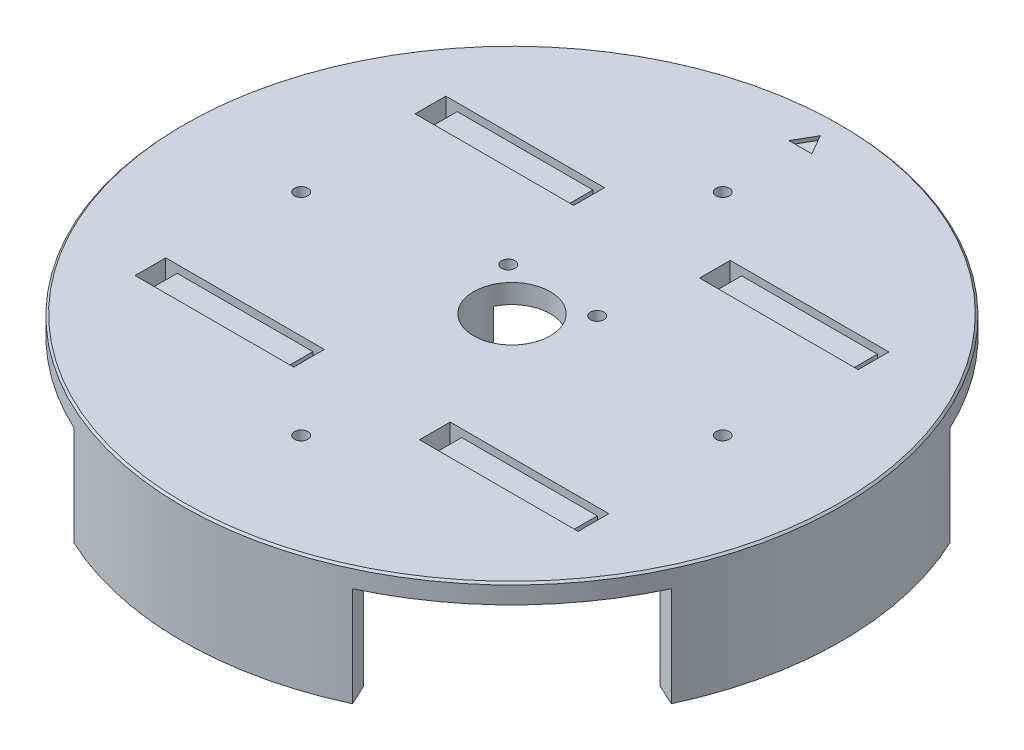
from build123d import *
from build123d.topology import SkipClean

# Parameters (mm, degrees)
SKIZZE1_R                       = 86
AUFSATZ_LINEAR_AUSTRAGEN1_DEPTH = 5
AUFSATZ_LINEAR_START            = 26
AUFSATZ_LINEAR_AUSTRAGEN2_DEPTH = 26
KREISMUSTER1_COUNT              = 4
SCHNITT_LINEAR_AUSTRAGEN1_REACH = 126.37
SKIZZE4_R                       = 10
AUFSATZ_LINEAR_AUSTRAGEN5_DEPTH = 26
SKIZZE6_R                       = 1.35
SCHNITT_LINEAR_AUSTRAGEN2_DEPTH = 10
KREISMUSTER2_COUNT              = 4
VERRUNDUNG3_R                   = 3
SCHNITT_LINEAR_AUSTRAGEN4_REACH = 126.37
SKIZZE10_W                      = 3
SKIZZE10_H                      = 8
FASE1_SIZE                      = 0.5
SCHNITT_LINEAR_AUSTRAGEN5_DEPTH = 1
SKIZZE12_R                      = 1.75
SCHNITT_LINEAR_AUSTRAGEN6_DEPTH = 5
SKIZZE13_W                      = 35.4
SKIZZE13_H                      = 8
SCHNITT_LINEAR_AUSTRAGEN7_DEPTH = 2


with BuildPart() as part:
    # Skizze1 → Aufsatz-Linear austragen1 (new body)
    with BuildSketch(Plane(origin=(0, 0, 0), x_dir=(1, 0, 0), z_dir=(0, 1, 0))):
        with Locations(Location((0, 0, 0), (0, 0, 270))):
            Circle(SKIZZE1_R)
    extrude(amount=AUFSATZ_LINEAR_AUSTRAGEN1_DEPTH)

    # Skizze2 → Aufsatz-Linear austragen2 (add)
    with SkipClean():  # the faces are left unmerged after this step: merging them gives an invalid solid
        with BuildSketch(Plane.XZ.offset(AUFSATZ_LINEAR_START)):
            with BuildLine():
                Line((-36.345171, 77.94247), (-33.809461, 72.504623))
                ThreePointArc((-33.809461, 72.504623), (0, 80), (33.809461, 72.504623))
                Line((33.809461, 72.504623), (36.345171, 77.94247))
                ThreePointArc((36.345171, 77.94247), (0, 86), (-36.345171, 77.94247))
            make_face()
        aufsatz_linear_austragen2 = extrude(amount=-AUFSATZ_LINEAR_AUSTRAGEN2_DEPTH)

    # Kreismuster1: Aufsatz-Linear austragen2 ×4 about axis
    with SkipClean():  # the faces are left unmerged after this step: merging them gives an invalid solid
        kreismuster1_axis = Axis((0, -99.932475, 0), (0, 1, 0))
        for i in range(1, KREISMUSTER1_COUNT):
            add(aufsatz_linear_austragen2.rotate(kreismuster1_axis, i * 360 / KREISMUSTER1_COUNT))

    # Skizze4 → Schnitt-Linear austragen1 (cut, up to next)
    with BuildSketch(Plane.XZ, mode=Mode.PRIVATE) as schnitt_linear_austragen1_sk1:
        with Locations(Location((0, 0, 0), (0, 0, 270))):
            Circle(SKIZZE4_R)
    schnitt_linear_austragen1_tool1 = extrude(schnitt_linear_austragen1_sk1.sketch, amount=-SCHNITT_LINEAR_AUSTRAGEN1_REACH, mode=Mode.PRIVATE) & part.part
    add(schnitt_linear_austragen1_tool1.solids().sort_by_distance((0, 0, 0))[0], mode=Mode.SUBTRACT)

    # Skizze7 → Aufsatz-Linear austragen5 (add)
    with SkipClean():  # the faces are left unmerged after this step: merging them gives an invalid solid
        with BuildSketch(Plane.XZ.offset(AUFSATZ_LINEAR_START)):
            with BuildLine():
                Line((-9.063078, 4.226183), (-11.782001, 5.494037))
                ThreePointArc((-11.782001, 5.494037), (-13, 0), (-11.782001, -5.494037))
                Line((-11.782001, -5.494037), (-9.063078, -4.226183))
                ThreePointArc((-9.063078, -4.226183), (-10, 0), (-9.063078, 4.226183))
            make_face()
            with BuildLine():
                ThreePointArc((13, 0), (12.691848, 2.813715), (11.782001, 5.494037))
                Line((11.782001, 5.494037), (9.063078, 4.226183))
                ThreePointArc((9.063078, 4.226183), (9.76296, 2.164396), (10, 0))
                ThreePointArc((10, 0), (9.76296, -2.164396), (9.063078, -4.226183))
                Line((9.063078, -4.226183), (11.782001, -5.494037))
                ThreePointArc((11.782001, -5.494037), (12.691848, -2.813715), (13, 0))
            make_face()
        extrude(amount=-AUFSATZ_LINEAR_AUSTRAGEN5_DEPTH)

    # Skizze6 → Schnitt-Linear austragen2 (cut)
    with SkipClean():  # the faces are left unmerged after this step: merging them gives an invalid solid
        with BuildSketch(Plane.XZ.offset(26)):
            with Locations(Location((-21.456083, 80.075191, 0), (0, 0, 270))):
                Circle(SKIZZE6_R)
            with Locations(Location((21.456083, 80.075191, 0), (0, 0, 270))):
                Circle(SKIZZE6_R)
        schnitt_linear_austragen2 = extrude(amount=-SCHNITT_LINEAR_AUSTRAGEN2_DEPTH, mode=Mode.SUBTRACT)

    # Kreismuster2: Schnitt-Linear austragen2 ×4 about axis
    with SkipClean():  # the faces are left unmerged after this step: merging them gives an invalid solid
        kreismuster2_axis = Axis((0, 0, 0), (0, 1, 0))
        for i in range(1, KREISMUSTER2_COUNT):
            add(schnitt_linear_austragen2.rotate(kreismuster2_axis, i * 360 / KREISMUSTER2_COUNT), mode=Mode.SUBTRACT)

    # Verrundung3
    verrundung3_edges = [part.edges().sort_by_distance(p)[0] for p in [
        (80, 0, 0),
        (0, 0, -80),
        (-80, 0, 0),
        (-13, 0, 0),
        (13, 0, 0),
        (0, 0, 80),
    ]]
    fillet(verrundung3_edges, radius=VERRUNDUNG3_R)

    # Skizze10 → Schnitt-Linear austragen4 (cut, up to next)
    with BuildSketch(Plane.XZ, mode=Mode.PRIVATE) as schnitt_linear_austragen4_sk1:
        with Locations((56.312567, 36.541606)):
            Rectangle(SKIZZE10_W, SKIZZE10_H)
    schnitt_linear_austragen4_tool1 = extrude(schnitt_linear_austragen4_sk1.sketch, amount=-SCHNITT_LINEAR_AUSTRAGEN4_REACH, mode=Mode.PRIVATE) & part.part
    # Skizze10 → Schnitt-Linear austragen4 (cut, up to next)
    with BuildSketch(Plane.XZ, mode=Mode.PRIVATE) as schnitt_linear_austragen4_sk2:
        with Locations((17.912567, 36.541606)):
            Rectangle(SKIZZE10_W, SKIZZE10_H)
    schnitt_linear_austragen4_tool2 = extrude(schnitt_linear_austragen4_sk2.sketch, amount=-SCHNITT_LINEAR_AUSTRAGEN4_REACH, mode=Mode.PRIVATE) & part.part
    # Skizze10 → Schnitt-Linear austragen4 (cut, up to next)
    with BuildSketch(Plane.XZ, mode=Mode.PRIVATE) as schnitt_linear_austragen4_sk3:
        with Locations((-17.912567, 36.541606)):
            Rectangle(SKIZZE10_W, SKIZZE10_H)
    schnitt_linear_austragen4_tool3 = extrude(schnitt_linear_austragen4_sk3.sketch, amount=-SCHNITT_LINEAR_AUSTRAGEN4_REACH, mode=Mode.PRIVATE) & part.part
    # Skizze10 → Schnitt-Linear austragen4 (cut, up to next)
    with BuildSketch(Plane.XZ, mode=Mode.PRIVATE) as schnitt_linear_austragen4_sk4:
        with Locations((-56.312567, 36.541606)):
            Rectangle(SKIZZE10_W, SKIZZE10_H)
    schnitt_linear_austragen4_tool4 = extrude(schnitt_linear_austragen4_sk4.sketch, amount=-SCHNITT_LINEAR_AUSTRAGEN4_REACH, mode=Mode.PRIVATE) & part.part
    # Skizze10 → Schnitt-Linear austragen4 (cut, up to next)
    with BuildSketch(Plane.XZ, mode=Mode.PRIVATE) as schnitt_linear_austragen4_sk5:
        with Locations((56.312567, -36.541606)):
            Rectangle(SKIZZE10_W, SKIZZE10_H)
    schnitt_linear_austragen4_tool5 = extrude(schnitt_linear_austragen4_sk5.sketch, amount=-SCHNITT_LINEAR_AUSTRAGEN4_REACH, mode=Mode.PRIVATE) & part.part
    # Skizze10 → Schnitt-Linear austragen4 (cut, up to next)
    with BuildSketch(Plane.XZ, mode=Mode.PRIVATE) as schnitt_linear_austragen4_sk6:
        with Locations((17.912567, -36.541606)):
            Rectangle(SKIZZE10_W, SKIZZE10_H)
    schnitt_linear_austragen4_tool6 = extrude(schnitt_linear_austragen4_sk6.sketch, amount=-SCHNITT_LINEAR_AUSTRAGEN4_REACH, mode=Mode.PRIVATE) & part.part
    # Skizze10 → Schnitt-Linear austragen4 (cut, up to next)
    with BuildSketch(Plane.XZ, mode=Mode.PRIVATE) as schnitt_linear_austragen4_sk7:
        with Locations((-17.912567, -36.541606)):
            Rectangle(SKIZZE10_W, SKIZZE10_H)
    schnitt_linear_austragen4_tool7 = extrude(schnitt_linear_austragen4_sk7.sketch, amount=-SCHNITT_LINEAR_AUSTRAGEN4_REACH, mode=Mode.PRIVATE) & part.part
    # Skizze10 → Schnitt-Linear austragen4 (cut, up to next)
    with BuildSketch(Plane.XZ, mode=Mode.PRIVATE) as schnitt_linear_austragen4_sk8:
        with Locations((-56.312567, -36.541606)):
            Rectangle(SKIZZE10_W, SKIZZE10_H)
    schnitt_linear_austragen4_tool8 = extrude(schnitt_linear_austragen4_sk8.sketch, amount=-SCHNITT_LINEAR_AUSTRAGEN4_REACH, mode=Mode.PRIVATE) & part.part
    add(schnitt_linear_austragen4_tool1.solids().sort_by_distance((56.312567, 0, 36.541606))[0], mode=Mode.SUBTRACT)
    add(schnitt_linear_austragen4_tool2.solids().sort_by_distance((17.912567, 0, 36.541606))[0], mode=Mode.SUBTRACT)
    add(schnitt_linear_austragen4_tool3.solids().sort_by_distance((-17.912567, 0, 36.541606))[0], mode=Mode.SUBTRACT)
    add(schnitt_linear_austragen4_tool4.solids().sort_by_distance((-56.312567, 0, 36.541606))[0], mode=Mode.SUBTRACT)
    add(schnitt_linear_austragen4_tool5.solids().sort_by_distance((56.312567, 0, -36.541606))[0], mode=Mode.SUBTRACT)
    add(schnitt_linear_austragen4_tool6.solids().sort_by_distance((17.912567, 0, -36.541606))[0], mode=Mode.SUBTRACT)
    add(schnitt_linear_austragen4_tool7.solids().sort_by_distance((-17.912567, 0, -36.541606))[0], mode=Mode.SUBTRACT)
    add(schnitt_linear_austragen4_tool8.solids().sort_by_distance((-56.312567, 0, -36.541606))[0], mode=Mode.SUBTRACT)

    # Fase1
    fase1_edges = [part.edges().sort_by_distance(p)[0] for p in [
        (0, 5, -86),
    ]]
    chamfer(fase1_edges, length=FASE1_SIZE)

    # Skizze11 → Schnitt-Linear austragen5 (cut)
    with SkipClean():  # the faces are left unmerged after this step: merging them gives an invalid solid
        with BuildSketch(Plane(origin=(0, 5, 0), x_dir=(1, 0, 0), z_dir=(0, 1, 0))):
            Polygon((3, 75.267949), (0, 80.464102), (-3, 75.267949), align=None)
        extrude(amount=-SCHNITT_LINEAR_AUSTRAGEN5_DEPTH, mode=Mode.SUBTRACT)

    # Skizze12 → Schnitt-Linear austragen6 (cut)
    with SkipClean():  # the faces are left unmerged after this step: merging them gives an invalid solid
        with BuildSketch(Plane.XZ):
            with Locations(Location((-55, 0, 0), (0, 0, 270))):
                Circle(SKIZZE12_R)
            with Locations(Location((0, -55, 0), (0, 0, 270))):
                Circle(SKIZZE12_R)
            with Locations(Location((55, 0, 0), (0, 0, 270))):
                Circle(SKIZZE12_R)
            with Locations(Location((0, 55, 0), (0, 0, 270))):
                Circle(SKIZZE12_R)
            with Locations(Location((-11.605237, -10.644187, 0), (0, 0, 270))):
                Circle(SKIZZE12_R)
            with Locations(Location((11.605237, -10.644187, 0), (0, 0, 270))):
                Circle(SKIZZE12_R)
        extrude(amount=-SCHNITT_LINEAR_AUSTRAGEN6_DEPTH, mode=Mode.SUBTRACT)

    # Skizze13 → Schnitt-Linear austragen7 (cut)
    with SkipClean():  # the faces are left unmerged after this step: merging them gives an invalid solid
        with BuildSketch(Plane(origin=(0, 5, 0), x_dir=(1, 0, 0), z_dir=(0, 1, 0))):
            with Locations((-37.112567, 36.541606)):
                Rectangle(SKIZZE13_W, SKIZZE13_H)
            with Locations((-37.112567, -36.541606)):
                Rectangle(SKIZZE13_W, SKIZZE13_H)
            with Locations((37.112567, -36.541606)):
                Rectangle(SKIZZE13_W, SKIZZE13_H)
            with Locations((37.112567, 36.541606)):
                Rectangle(SKIZZE13_W, SKIZZE13_H)
        extrude(amount=-SCHNITT_LINEAR_AUSTRAGEN7_DEPTH, mode=Mode.SUBTRACT)


solid = part.part
